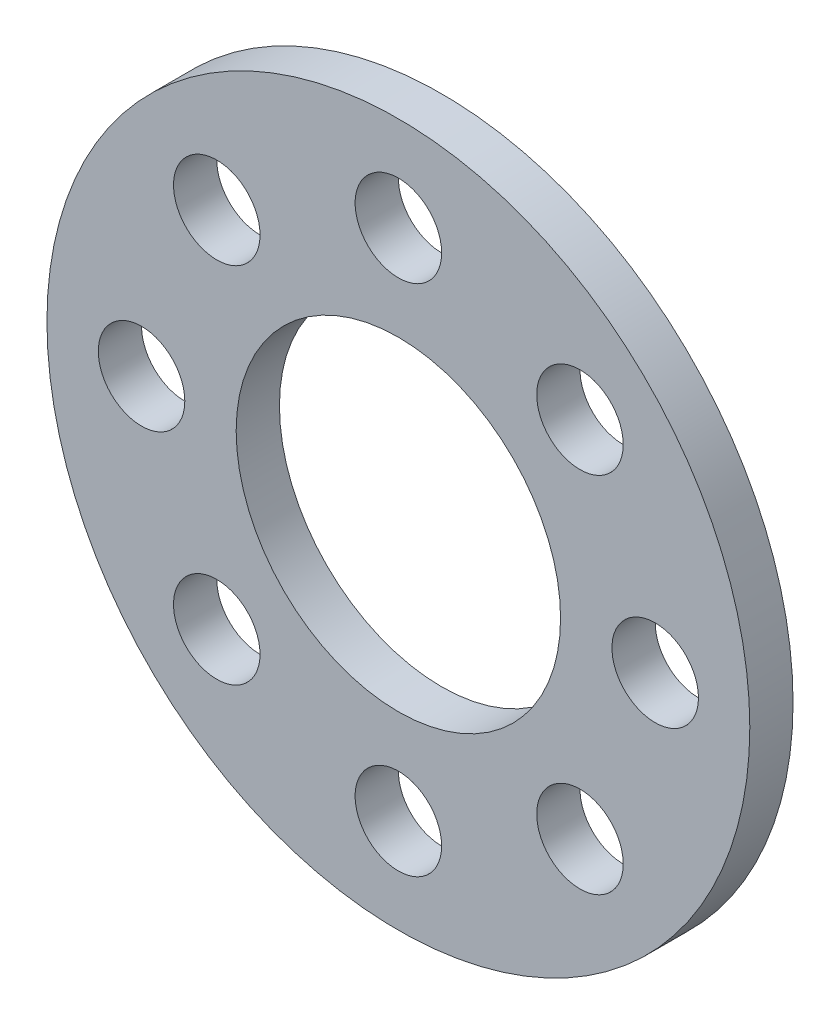
from build123d import *

# Parameters (mm, degrees)
ESQUISSE1_R        = 16.25
ESQUISSE1_R_2      = 7.5
ESQUISSE1_R_3      = 2
BOSS_EXTRU_1_DEPTH = 2


with BuildPart() as part:
    # Esquisse1 → Boss.-Extru.1 (new body)
    with BuildSketch(Plane.XY):
        Circle(ESQUISSE1_R)
        Circle(ESQUISSE1_R_2, mode=Mode.SUBTRACT)
        with Locations((0, 11.875)):
            Circle(ESQUISSE1_R_3, mode=Mode.SUBTRACT)
        with Locations((8.396893027, 8.396893027)):
            Circle(ESQUISSE1_R_3, mode=Mode.SUBTRACT)
        with Locations((11.875, 0)):
            Circle(ESQUISSE1_R_3, mode=Mode.SUBTRACT)
        with Locations((8.396893027, -8.396893027)):
            Circle(ESQUISSE1_R_3, mode=Mode.SUBTRACT)
        with Locations((0, -11.875)):
            Circle(ESQUISSE1_R_3, mode=Mode.SUBTRACT)
        with Locations((-8.396893027, -8.396893027)):
            Circle(ESQUISSE1_R_3, mode=Mode.SUBTRACT)
        with Locations((-11.875, 0)):
            Circle(ESQUISSE1_R_3, mode=Mode.SUBTRACT)
        with Locations((-8.396893027, 8.396893027)):
            Circle(ESQUISSE1_R_3, mode=Mode.SUBTRACT)
    extrude(amount=BOSS_EXTRU_1_DEPTH)


solid = part.part
